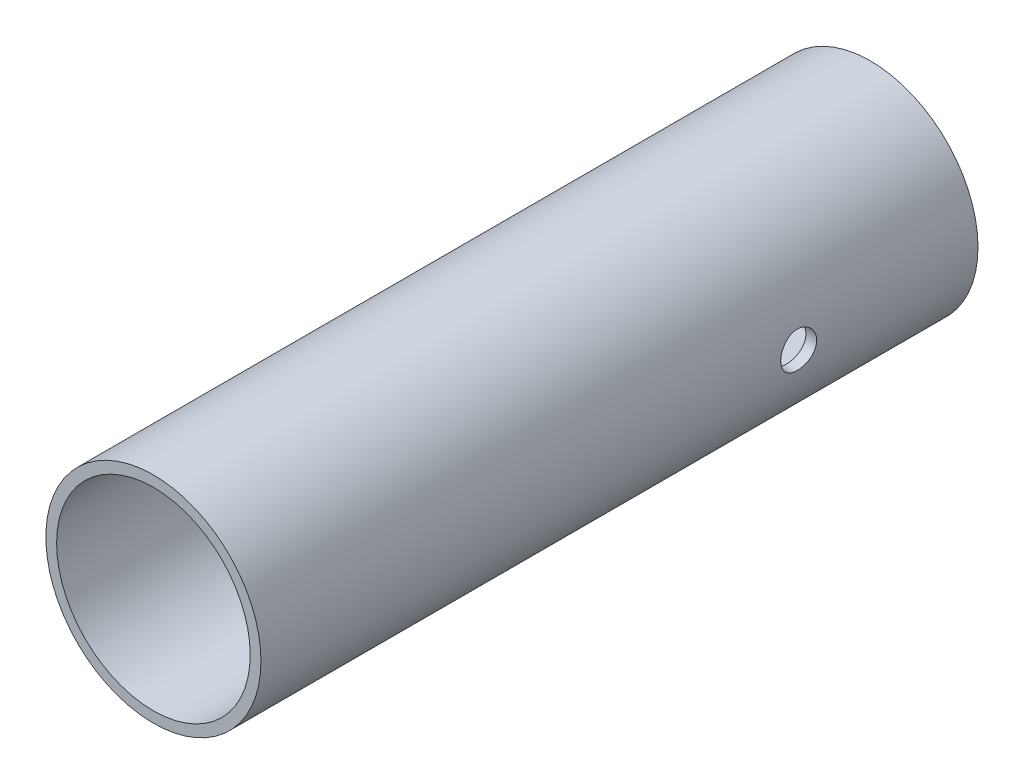
from build123d import *

# Parameters (mm, degrees)
SZKIC2_R                              = 30
SZKIC2_R_2                            = 27
DODANIE_WYCI_GNI_CIE4_DEPTH           = 200
OTWORY_USTALAJ_CE_10_0MM1_D           = 10
OTWORY_USTALAJ_CE_10_0MM1_CSINK_D     = 10.05
OTWORY_USTALAJ_CE_10_0MM1_CSINK_ANGLE = 90


with BuildPart() as part:
    # Szkic2 → Dodanie-wyciągnięcie4 (new body)
    with BuildSketch(Plane.XY):
        Circle(SZKIC2_R)
        Circle(SZKIC2_R_2, mode=Mode.SUBTRACT)
    extrude(amount=DODANIE_WYCI_GNI_CIE4_DEPTH)

    # Otwory ustalające Ø10.0mm1 (through all)
    with Locations(Plane(origin=(30, 0, 50), x_dir=(0, 1, 0), z_dir=(1, 0, 0))):
        with Locations((0, 0)):
            CounterSinkHole(OTWORY_USTALAJ_CE_10_0MM1_D / 2, OTWORY_USTALAJ_CE_10_0MM1_CSINK_D / 2, counter_sink_angle=OTWORY_USTALAJ_CE_10_0MM1_CSINK_ANGLE)


solid = part.part
